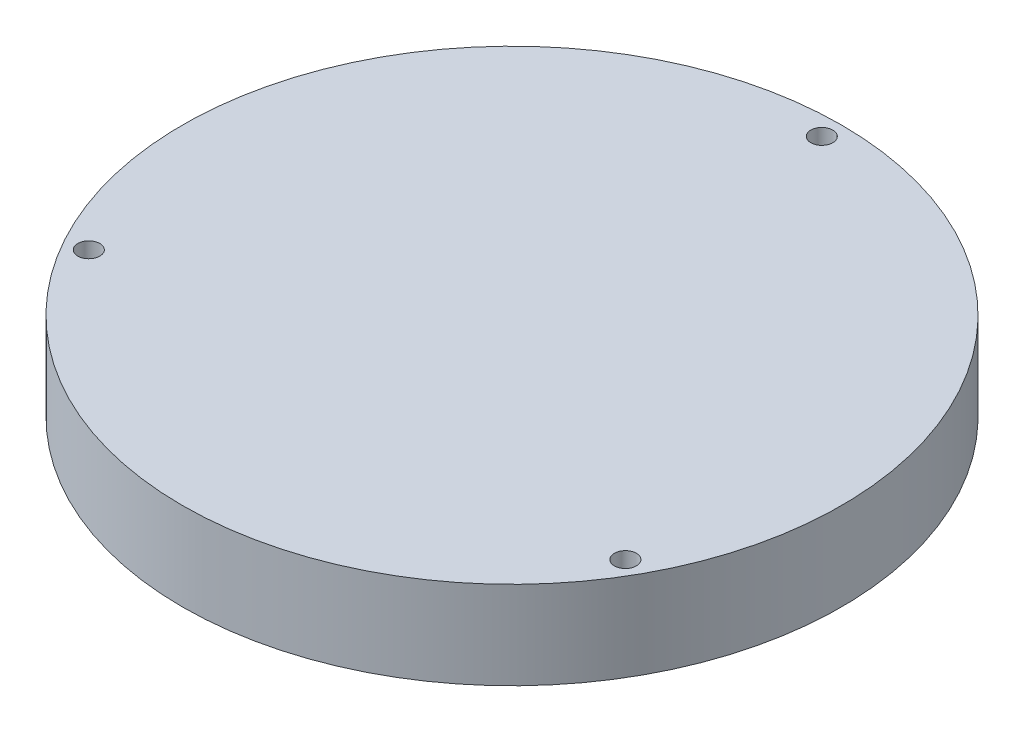
from build123d import *

# Parameters (mm, degrees)
SKETCH1_R           = 95.25
BOSS_EXTRUDE1_DEPTH = 12.7
SKETCH2_R           = 3.175
CUT_EXTRUDE1_DEPTH  = 26.4
CIRPATTERN1_COUNT   = 3
SKETCH3_R           = 2.8448
CUT_EXTRUDE2_DEPTH  = 12.7
CIRPATTERN2_COUNT   = 3


with BuildPart() as part:
    # Sketch1 → Boss-Extrude1 (new body, symmetric)
    with BuildSketch(Plane(origin=(0, 0, 0), x_dir=(1, 0, 0), z_dir=(0, 1, 0))):
        Circle(SKETCH1_R)
    extrude(amount=BOSS_EXTRUDE1_DEPTH, both=True)

    # Sketch2 → Cut-Extrude1 (cut, through all)
    with BuildSketch(Plane(origin=(0, 12.7, 0), x_dir=(1, 0, 0), z_dir=(0, 1, 0))):
        with Locations((0, 89.535)):
            Circle(SKETCH2_R)
    cut_extrude1 = extrude(amount=-CUT_EXTRUDE1_DEPTH, mode=Mode.SUBTRACT)

    # CirPattern1: Cut-Extrude1 ×3 about axis
    cirpattern1_axis = Axis((0, 0, 0), (0, 1, 0))
    for i in range(1, CIRPATTERN1_COUNT):
        add(cut_extrude1.rotate(cirpattern1_axis, i * 360 / CIRPATTERN1_COUNT), mode=Mode.SUBTRACT)

    # Sketch3 → Cut-Extrude2 (cut)
    with BuildSketch(Plane(origin=(0, -12.7, 0), x_dir=(-1, 0, 0), z_dir=(0, -1, 0))):
        with Locations((-77.539584528, 44.7675)):
            Circle(SKETCH3_R)
    cut_extrude2 = extrude(amount=-CUT_EXTRUDE2_DEPTH, mode=Mode.SUBTRACT)

    # CirPattern2: Cut-Extrude2 ×3 about axis
    cirpattern2_axis = Axis((0, 0, 0), (0, 1, 0))
    for i in range(1, CIRPATTERN2_COUNT):
        add(cut_extrude2.rotate(cirpattern2_axis, i * 360 / CIRPATTERN2_COUNT), mode=Mode.SUBTRACT)


solid = part.part
